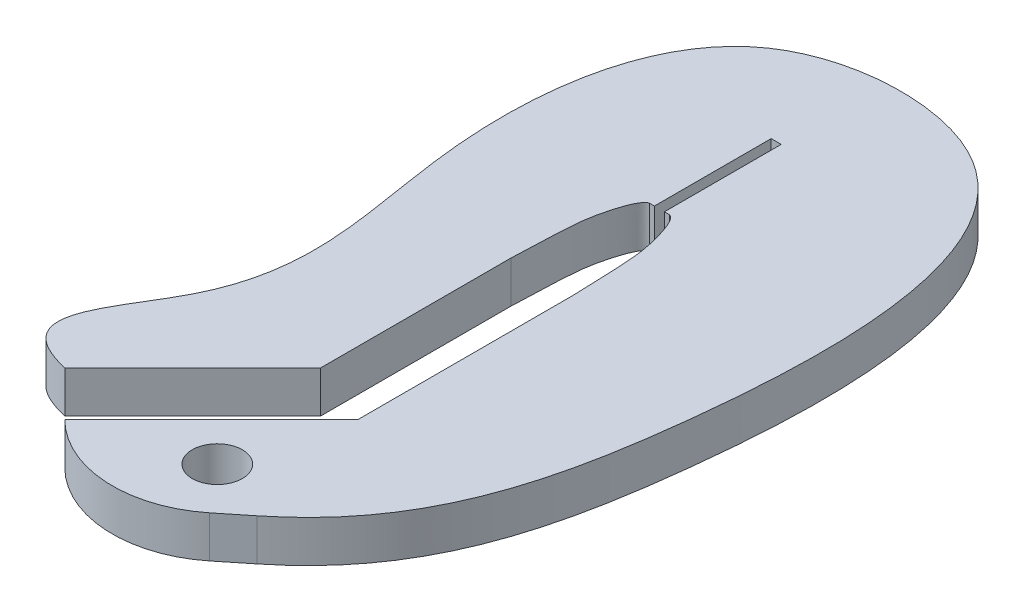
from build123d import *

# Parameters (mm, degrees)
SKETCH1_R           = 1.5
BOSS_EXTRUDE1_DEPTH = 2.5


with BuildPart() as part:
    # Sketch1 → Boss-Extrude1 (new body)
    with BuildSketch(Plane(origin=(0, 0, 0), x_dir=(1, 0, 0), z_dir=(0, 1, 0))):
        with BuildLine():
            Line((0.6, 0.6), (0.6, 12))
            add(Edge.make_bspline(
                [(0.6, 12), (0.705879385, 15.531728995), (0.830348084, 16.200108902), (0.963303185, 16.979764987), (1.42899004, 18.896334129), (1.9, 19)],
                knots=[0, 0, 0, 0, 0.421520608, 0.521520608, 1, 1, 1, 1], degree=3))
            Line((1.9, 19), (2.2, 19))
            Line((2.2, 19), (2.2, 26))
            Line((2.2, 26), (2.8, 26))
            Line((2.8, 26), (2.8, 19))
            Line((2.8, 19), (3.1, 19))
            add(Edge.make_bspline(
                [(4.4, 12), (4.294120615, 15.531728995), (4.169651916, 16.200108902), (4.036696815, 16.979764987), (3.57100996, 18.896334129), (3.1, 19)],
                knots=[0, 0, 0, 0, 0.421520608, 0.521520608, 1, 1, 1, 1], degree=3))
            Line((4.4, 12), (4.4, -0.974011537))
            Line((4.4, -0.974011537), (-4.384062043, -9.75807358))
            ThreePointArc((-4.384062043, -9.75807358), (0.112087391, -11.763979662), (4.797889936, -10.253260144))
            ThreePointArc((4.797889936, -10.253260144), (5.582615722, -9.622063145), (6.36765924, -8.991261367))
            add(Edge.make_bspline(
                [(6.36765924, -8.991261367), (8.335921286, -7.410529729), (12.442286463, -2.475816032), (15.274328452, 11.372078595), (15.399585069, 33.191681109), (-6.202311682, 32.469118273), (-8.068966361, 15.05631667), (-3.371060807, 2.766408617), (-12.021291616, -5.932835632), (-7.071067812, -7.071067812)],
                knots=[0.011628468, 0.011628468, 0.011628468, 0.011628468, 0.081877786, 0.220720337, 0.462998597, 0.579337122, 0.740821042, 0.900192676, 1, 1, 1, 1], degree=3))
            Line((-7.071067812, -7.071067812), (0.6, 0.6))
        make_face()
        with Locations((2.5, -7.5)):
            Circle(SKETCH1_R, mode=Mode.SUBTRACT)
    extrude(amount=BOSS_EXTRUDE1_DEPTH)


solid = part.part
